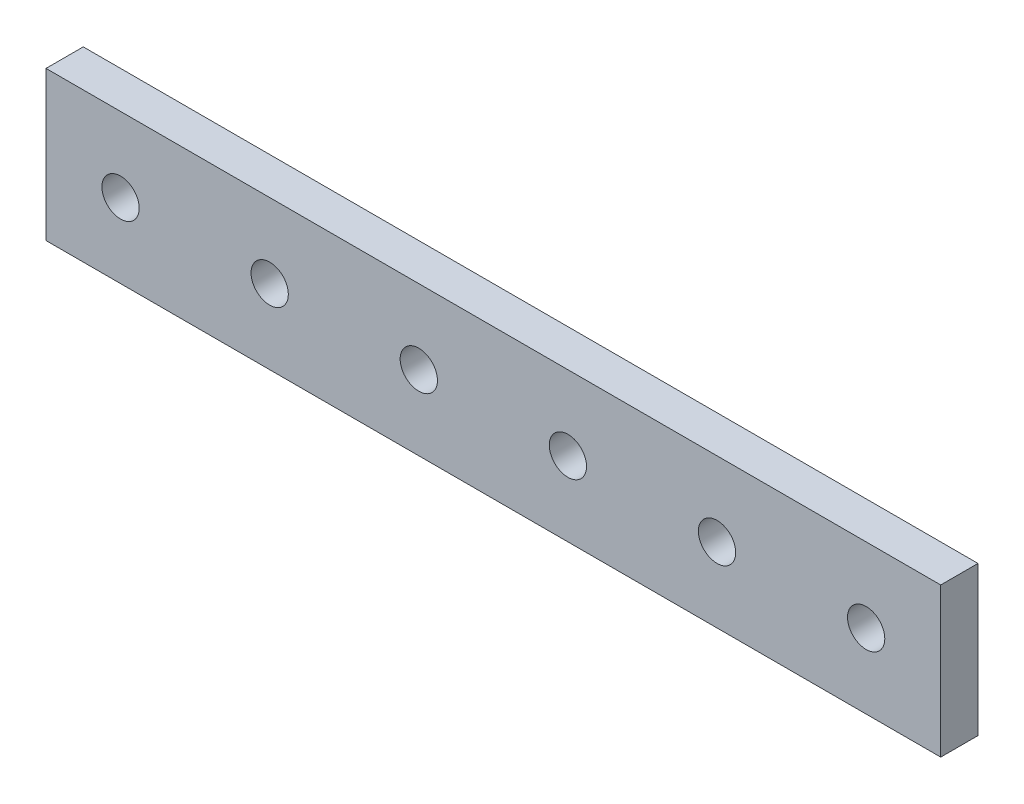
from build123d import *

# Parameters (mm, degrees)
SKETCH1_W           = 152.4
SKETCH1_H           = 25.4
BOSS_EXTRUDE1_DEPTH = 6.35
SKETCH2_R           = 3.175
CUT_EXTRUDE1_DEPTH  = 6.35


with BuildPart() as part:
    # Sketch1 → Boss-Extrude1 (new body)
    with BuildSketch(Plane.XY):
        Rectangle(SKETCH1_W, SKETCH1_H)
    extrude(amount=BOSS_EXTRUDE1_DEPTH)

    # Sketch2 → Cut-Extrude1 (cut)
    with BuildSketch(Plane.XY.offset(6.35)):
        with Locations((-12.7, 0)):
            Circle(SKETCH2_R)
        with Locations((38.1, 0)):
            Circle(SKETCH2_R)
        with Locations((63.5, 0)):
            Circle(SKETCH2_R)
        with Locations((12.7, 0)):
            Circle(SKETCH2_R)
        with Locations((-38.1, 0)):
            Circle(SKETCH2_R)
        with Locations((-63.5, 0)):
            Circle(SKETCH2_R)
    extrude(amount=-CUT_EXTRUDE1_DEPTH, mode=Mode.SUBTRACT)


solid = part.part
